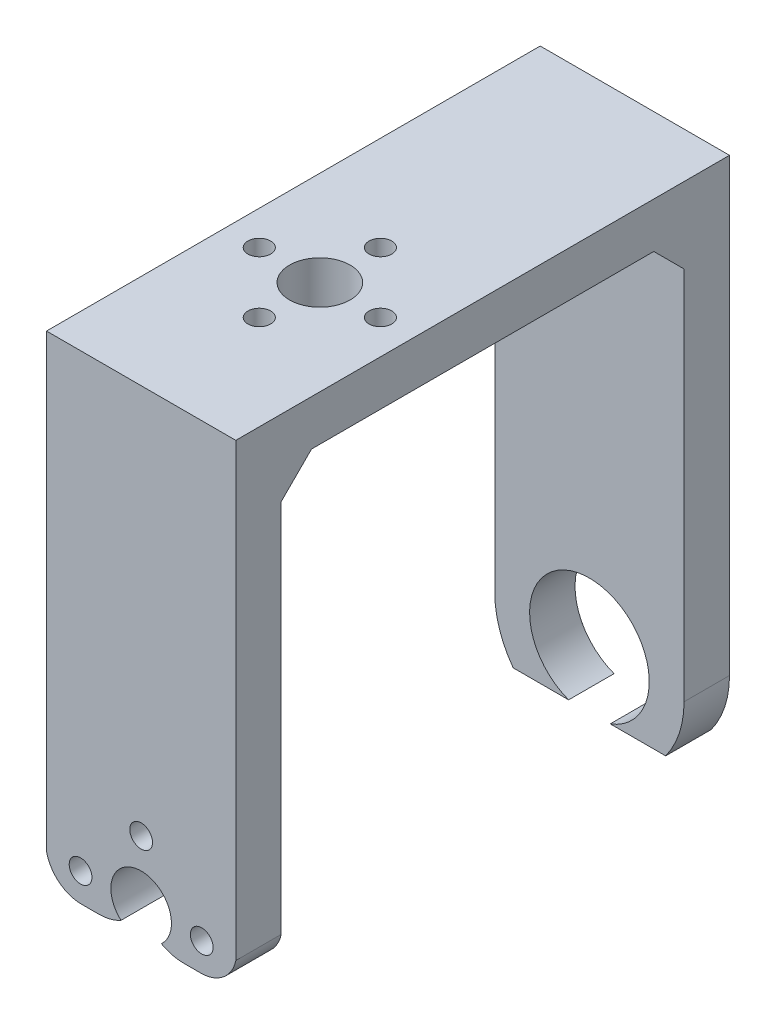
from build123d import *

# Parameters (mm, degrees)
SALIENTE_EXTRUIR1_DEPTH = 25
CORTAR_EXTRUIR2_REACH   = 67.2
CORTAR_EXTRUIR3_REACH   = 72
CROQUIS4_R              = 1.5
CROQUIS4_R_2            = 4
CHAFL_N1_SIZE           = 4
CORTAR_EXTRUIR5_REACH   = 67.2
CROQUIS8_R              = 1.5


with BuildPart() as part:
    # Croquis1 → Saliente-Extruir1 (new body)
    with BuildSketch(Plane(origin=(0, 0, 0), x_dir=(0, 0, -1), z_dir=(1, 0, 0))):
        Polygon((-26.6, -20.333615037), (-26.6, 43.666384963), (26.6, 43.666384963), (26.6, -20.333615037), (32.6, -20.333615037), (32.6, 49.666384963), (-32.6, 49.666384963), (-32.6, -20.333615037), align=None)
    extrude(amount=SALIENTE_EXTRUIR1_DEPTH)

    # Croquis3 → Cortar-Extruir2 (cut, up to next)
    with BuildSketch(Plane(origin=(0, 0, -32.6), x_dir=(-1, 0, 0), z_dir=(0, 0, -1)), mode=Mode.PRIVATE) as cortar_extruir2_sk1:
        with BuildLine():
            Line((-15.246347098, -17.240880228), (-22.56888387, -17.240880228))
            ThreePointArc((-22.56888387, -17.240880228), (-24.376679847, -13.731624248), (-25, -9.833615037))
            Line((-25, -9.833615037), (-25, -20.333615037))
            Line((-25, -20.333615037), (0, -20.333615037))
            Line((0, -20.333615037), (0, -9.833615037))
            ThreePointArc((0, -9.833615037), (-0.623320153, -13.731624248), (-2.43111613, -17.240880228))
            Line((-2.43111613, -17.240880228), (-9.753652902, -17.240880228))
            ThreePointArc((-9.753652902, -17.240880228), (-12.5, -1.933615037), (-15.246347098, -17.240880228))
        make_face()
    cortar_extruir2_tool1 = extrude(cortar_extruir2_sk1.sketch, amount=-CORTAR_EXTRUIR2_REACH, mode=Mode.PRIVATE) & part.part
    add(cortar_extruir2_tool1.solids().sort_by_distance((12.5, -12.457644, -32.6))[0], mode=Mode.SUBTRACT)

    # Croquis4 → Cortar-Extruir3 (cut, up to next)
    with BuildSketch(Plane(origin=(0, 49.666384963, 0), x_dir=(1, 0, 0), z_dir=(0, 1, 0)), mode=Mode.PRIVATE) as cortar_extruir3_sk1:
        with Locations((12.5, -1)):
            Circle(CROQUIS4_R)
    cortar_extruir3_tool1 = extrude(cortar_extruir3_sk1.sketch, amount=-CORTAR_EXTRUIR3_REACH, mode=Mode.PRIVATE) & part.part
    add(cortar_extruir3_tool1.solids().sort_by_distance((12.5, 49.666385, 1))[0], mode=Mode.SUBTRACT)
    # Croquis4 → Cortar-Extruir3 (cut, up to next)
    with BuildSketch(Plane(origin=(0, 49.666384963, 0), x_dir=(1, 0, 0), z_dir=(0, 1, 0)), mode=Mode.PRIVATE) as cortar_extruir3_sk2:
        with Locations((4.5, -9)):
            Circle(CROQUIS4_R)
    cortar_extruir3_tool2 = extrude(cortar_extruir3_sk2.sketch, amount=-CORTAR_EXTRUIR3_REACH, mode=Mode.PRIVATE) & part.part
    add(cortar_extruir3_tool2.solids().sort_by_distance((4.5, 49.666385, 9))[0], mode=Mode.SUBTRACT)
    # Croquis4 → Cortar-Extruir3 (cut, up to next)
    with BuildSketch(Plane(origin=(0, 49.666384963, 0), x_dir=(1, 0, 0), z_dir=(0, 1, 0)), mode=Mode.PRIVATE) as cortar_extruir3_sk3:
        with Locations((12.5, -17)):
            Circle(CROQUIS4_R)
    cortar_extruir3_tool3 = extrude(cortar_extruir3_sk3.sketch, amount=-CORTAR_EXTRUIR3_REACH, mode=Mode.PRIVATE) & part.part
    add(cortar_extruir3_tool3.solids().sort_by_distance((12.5, 49.666385, 17))[0], mode=Mode.SUBTRACT)
    # Croquis4 → Cortar-Extruir3 (cut, up to next)
    with BuildSketch(Plane(origin=(0, 49.666384963, 0), x_dir=(1, 0, 0), z_dir=(0, 1, 0)), mode=Mode.PRIVATE) as cortar_extruir3_sk4:
        with Locations((20.5, -9)):
            Circle(CROQUIS4_R)
    cortar_extruir3_tool4 = extrude(cortar_extruir3_sk4.sketch, amount=-CORTAR_EXTRUIR3_REACH, mode=Mode.PRIVATE) & part.part
    add(cortar_extruir3_tool4.solids().sort_by_distance((20.5, 49.666385, 9))[0], mode=Mode.SUBTRACT)
    # Croquis4 → Cortar-Extruir3 (cut, up to next)
    with BuildSketch(Plane(origin=(0, 49.666384963, 0), x_dir=(1, 0, 0), z_dir=(0, 1, 0)), mode=Mode.PRIVATE) as cortar_extruir3_sk5:
        with Locations((12.5, -9)):
            Circle(CROQUIS4_R_2)
    cortar_extruir3_tool5 = extrude(cortar_extruir3_sk5.sketch, amount=-CORTAR_EXTRUIR3_REACH, mode=Mode.PRIVATE) & part.part
    add(cortar_extruir3_tool5.solids().sort_by_distance((12.5, 49.666385, 9))[0], mode=Mode.SUBTRACT)

    # Chaflán1
    chafl_n1_edges = [part.edges().sort_by_distance(p)[0] for p in [
        (12.5, 43.666384963, -26.6),
        (12.5, 43.666384963, 26.6),
    ]]
    chamfer(chafl_n1_edges, length=CHAFL_N1_SIZE)

    # Croquis8 → Cortar-Extruir5 (cut, up to next)
    with BuildSketch(Plane.XY.offset(32.6), mode=Mode.PRIVATE) as cortar_extruir5_sk1:
        with Locations((4.5, -9.833615037)):
            Circle(CROQUIS8_R)
    cortar_extruir5_tool1 = extrude(cortar_extruir5_sk1.sketch, amount=-CORTAR_EXTRUIR5_REACH, mode=Mode.PRIVATE) & part.part
    add(cortar_extruir5_tool1.solids().sort_by_distance((4.5, -9.833615, 32.6))[0], mode=Mode.SUBTRACT)
    # Croquis8 → Cortar-Extruir5 (cut, up to next)
    with BuildSketch(Plane.XY.offset(32.6), mode=Mode.PRIVATE) as cortar_extruir5_sk2:
        with Locations((12.5, -1.833615037)):
            Circle(CROQUIS8_R)
    cortar_extruir5_tool2 = extrude(cortar_extruir5_sk2.sketch, amount=-CORTAR_EXTRUIR5_REACH, mode=Mode.PRIVATE) & part.part
    add(cortar_extruir5_tool2.solids().sort_by_distance((12.5, -1.833615, 32.6))[0], mode=Mode.SUBTRACT)
    # Croquis8 → Cortar-Extruir5 (cut, up to next)
    with BuildSketch(Plane.XY.offset(32.6), mode=Mode.PRIVATE) as cortar_extruir5_sk3:
        with Locations((20.5, -9.833615037)):
            Circle(CROQUIS8_R)
    cortar_extruir5_tool3 = extrude(cortar_extruir5_sk3.sketch, amount=-CORTAR_EXTRUIR5_REACH, mode=Mode.PRIVATE) & part.part
    add(cortar_extruir5_tool3.solids().sort_by_distance((20.5, -9.833615, 32.6))[0], mode=Mode.SUBTRACT)
    # Croquis8 → Cortar-Extruir5 (cut, up to next)
    with BuildSketch(Plane.XY.offset(32.6), mode=Mode.PRIVATE) as cortar_extruir5_sk4:
        with BuildLine():
            Line((4.605097731, -13.578746505), (6.89606083, -13.578746505))
            ThreePointArc((6.89606083, -13.578746505), (8.414491828, -13.385028449), (9.836162211, -12.817566818))
            ThreePointArc((9.836162211, -12.817566818), (12.5, -5.833615037), (15.163837789, -12.817566818))
            ThreePointArc((15.163837789, -12.817566818), (16.585508172, -13.385028449), (18.10393917, -13.578746505))
            Line((18.10393917, -13.578746505), (20.394902269, -13.578746505))
            ThreePointArc((20.394902269, -13.578746505), (23.36276913, -12.524270715), (25, -9.833615037))
            Line((25, -9.833615037), (25, -20.333615037))
            Line((25, -20.333615037), (0, -20.333615037))
            Line((0, -20.333615037), (0, -9.833615037))
            ThreePointArc((0, -9.833615037), (1.63723087, -12.524270715), (4.605097731, -13.578746505))
        make_face()
    cortar_extruir5_tool4 = extrude(cortar_extruir5_sk4.sketch, amount=-CORTAR_EXTRUIR5_REACH, mode=Mode.PRIVATE) & part.part
    add(cortar_extruir5_tool4.solids().sort_by_distance((12.5, -15.203922, 32.6))[0], mode=Mode.SUBTRACT)


solid = part.part
